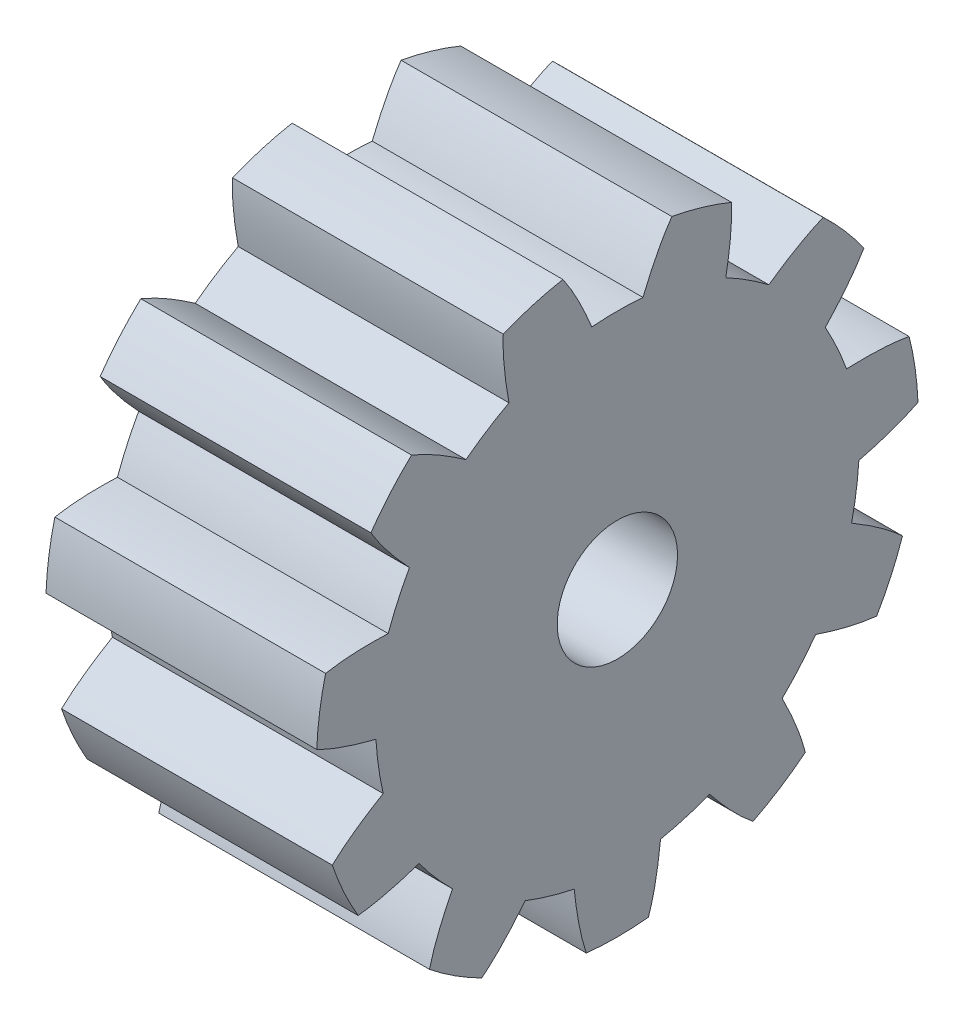
from build123d import *

# Parameters (mm, degrees)
SKETCH2_R           = 10
SKETCH2_R_2         = 1
BOSS_EXTRUDE2_DEPTH = 9
CUT_EXTRUDE4_DEPTH  = 10
CIRPATTERN2_COUNT   = 11
SKETCH7_R           = 2
SKETCH7_R_2         = 1
CUT_EXTRUDE5_DEPTH  = 7.5


with BuildPart() as part:
    # Sketch2 → Boss-Extrude2 (new body)
    with BuildSketch(Plane(origin=(0, 0, 0), x_dir=(0, 0, -1), z_dir=(1, 0, 0))):
        Circle(SKETCH2_R)
        Circle(SKETCH2_R_2, mode=Mode.SUBTRACT)
    extrude(amount=BOSS_EXTRUDE2_DEPTH)

    # Sketch6 → Cut-Extrude4 (cut, symmetric)
    with BuildSketch(Plane(origin=(0, 0, 0), x_dir=(0, 0, -1), z_dir=(1, 0, 0))):
        with BuildLine():
            ThreePointArc((1.85, 9.889708377), (0, 10.025881913), (-1.85, 9.889708377))
            add(Edge.make_bspline(
                [(-0.85, 7.986983034), (-1.133345999, 8.672201219), (-1.446471777, 9.32650192), (-1.85, 9.889708377)],
                knots=[0.309355195, 0.309355195, 0.309355195, 0.309355195, 0.515063523, 0.515063523, 0.515063523, 0.515063523], degree=3))
            ThreePointArc((-0.85, 7.986983034), (0, 8.021021821), (0.85, 7.986983034))
            add(Edge.make_bspline(
                [(0.85, 7.986983034), (1.133345999, 8.672201219), (1.446471777, 9.32650192), (1.85, 9.889708377)],
                knots=[0.309355195, 0.309355195, 0.309355195, 0.309355195, 0.515063523, 0.515063523, 0.515063523, 0.515063523], degree=3))
        make_face()
    cut_extrude4 = extrude(amount=CUT_EXTRUDE4_DEPTH, both=True, mode=Mode.SUBTRACT)

    # CirPattern2: Cut-Extrude4 ×11 about axis
    cirpattern2_axis = Axis((9, 0, 0), (-1, 0, 0))
    for i in range(1, CIRPATTERN2_COUNT):
        add(cut_extrude4.rotate(cirpattern2_axis, i * 360 / CIRPATTERN2_COUNT), mode=Mode.SUBTRACT)

    # Sketch7 → Cut-Extrude5 (cut)
    with BuildSketch(Plane(origin=(9, 0, 0), x_dir=(0, 0, -1), z_dir=(1, 0, 0))):
        Circle(SKETCH7_R)
        Circle(SKETCH7_R_2, mode=Mode.SUBTRACT)
    extrude(amount=-CUT_EXTRUDE5_DEPTH, mode=Mode.SUBTRACT)


solid = part.part
